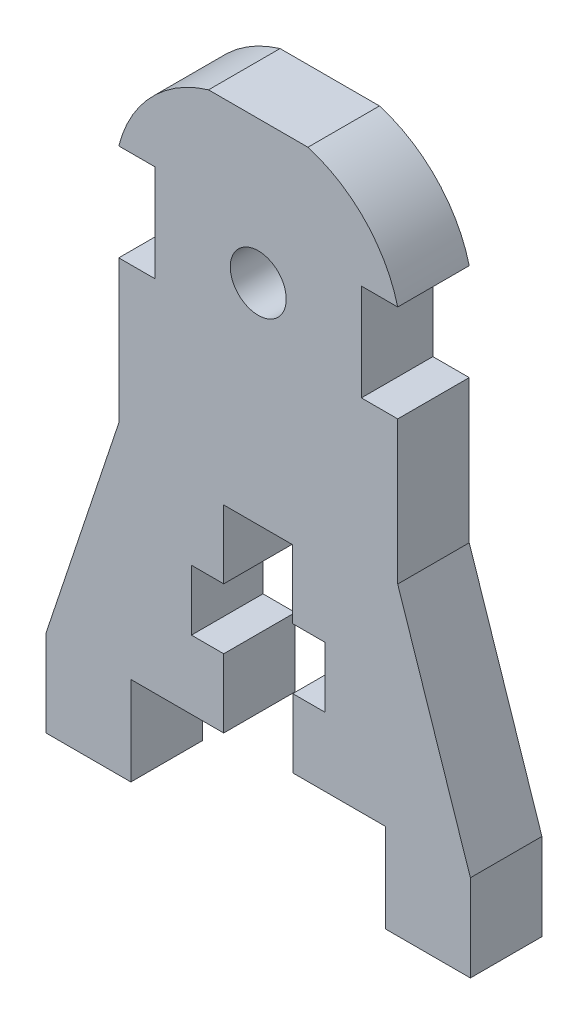
from build123d import *

# Parameters (mm, degrees)
SKETCH1_R           = 1.955
BOSS_EXTRUDE1_DEPTH = 5


with BuildPart() as part:
    # Sketch1 → Boss-Extrude1 (new body)
    with BuildSketch(Plane.XY):
        with BuildLine():
            Line((-46.205346306, 6.069), (-46.205346306, 0))
            Line((-46.205346306, 0), (-40.278346306, 0))
            Line((-40.278346306, 0), (-40.278346306, 6.209))
            Line((-40.278346306, 6.209), (-33.788346306, 6.209))
            Line((-33.788346306, 6.209), (-33.788346306, 11.008))
            Line((-33.788346306, 11.008), (-36.045346306, 11.008))
            Line((-36.045346306, 11.008), (-36.045346306, 15.241))
            Line((-36.045346306, 15.241), (-33.787346306, 15.241))
            Line((-33.787346306, 15.241), (-33.787346306, 20.018965401))
            Line((-33.787346306, 20.018965401), (-31.375346306, 20.018965401))
            Line((-31.375346306, 20.018965401), (-28.963346306, 20.018965401))
            Line((-28.963346306, 20.018965401), (-28.963346306, 15.241))
            Line((-28.963346306, 15.241), (-26.705346306, 15.241))
            Line((-26.705346306, 15.241), (-26.705346306, 11.008))
            Line((-26.705346306, 11.008), (-28.962346306, 11.008))
            Line((-28.962346306, 11.008), (-28.962346306, 6.209))
            Line((-28.962346306, 6.209), (-22.472346306, 6.209))
            Line((-22.472346306, 6.209), (-22.472346306, 0))
            Line((-22.472346306, 0), (-16.545346306, 0))
            Line((-16.545346306, 0), (-16.545346306, 6.069))
            Line((-16.545346306, 6.069), (-21.625346306, 21.309))
            Line((-21.625346306, 21.309), (-21.625346306, 31.309))
            Line((-21.625346306, 31.309), (-24.165346306, 31.309))
            Line((-24.165346306, 31.309), (-24.165346306, 38.082))
            Line((-24.165346306, 38.082), (-21.625346306, 38.082))
            ThreePointArc((-21.625346306, 38.082), (-23.900792185, 42.177151256), (-27.90009545, 44.61712895))
            Line((-27.90009545, 44.61712895), (-31.366233796, 44.61712895))
            Line((-31.366233796, 44.61712895), (-31.384458817, 44.61712895))
            Line((-31.384458817, 44.61712895), (-34.850597163, 44.61712895))
            ThreePointArc((-34.850597163, 44.61712895), (-38.849900428, 42.177151256), (-41.125346306, 38.082))
            Line((-41.125346306, 38.082), (-38.585346306, 38.082))
            Line((-38.585346306, 38.082), (-38.585346306, 31.309))
            Line((-38.585346306, 31.309), (-41.125346306, 31.309))
            Line((-41.125346306, 31.309), (-41.125346306, 21.309))
            Line((-41.125346306, 21.309), (-46.205346306, 6.069))
        make_face()
        with Locations((-31.375346306, 34.658965401)):
            Circle(SKETCH1_R, mode=Mode.SUBTRACT)
    extrude(amount=BOSS_EXTRUDE1_DEPTH)


solid = part.part
